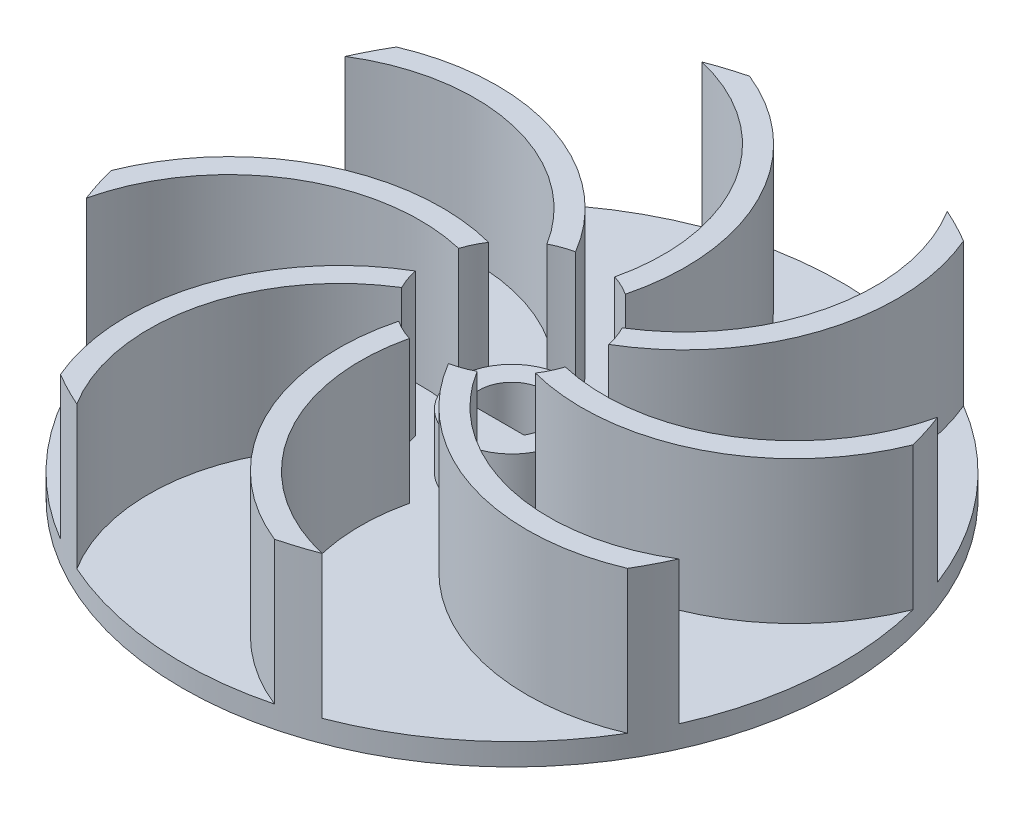
from build123d import *

# Parameters (mm, degrees)
SKETCH1_R           = 30
BOSS_EXTRUDE1_DEPTH = 2
SKETCH2_R           = 5
BOSS_EXTRUDE2_DEPTH = 7
BOSS_EXTRUDE3_DEPTH = 13
CUT_EXTRUDE1_DEPTH  = 16
CIRPATTERN2_COUNT   = 8


with BuildPart() as part:
    # Sketch1 → Boss-Extrude1 (new body)
    with BuildSketch(Plane(origin=(0, 0, 0), x_dir=(1, 0, 0), z_dir=(0, 1, 0))):
        Circle(SKETCH1_R)
    extrude(amount=BOSS_EXTRUDE1_DEPTH)

    # Sketch2 → Boss-Extrude2 (add)
    with BuildSketch(Plane(origin=(0, 0, 0), x_dir=(1, 0, 0), z_dir=(0, 1, 0))):
        Circle(SKETCH2_R)
    extrude(amount=BOSS_EXTRUDE2_DEPTH)

    # Sketch3 → Boss-Extrude3 (add)
    with BuildSketch(Plane(origin=(0, 2, 0), x_dir=(1, 0, 0), z_dir=(0, 1, 0))):
        with BuildLine():
            ThreePointArc((-1.505806951, 7.292266896), (-12.151790035, 15.86929072), (-25.810761164, 15.290670625))
            ThreePointArc((-25.810761164, 15.290670625), (-26.649690738, 13.776573724), (-27.399897799, 12.216611666))
            ThreePointArc((-27.399897799, 12.216611666), (-14.251932533, 14.383859932), (-3.429686075, 6.60922571))
            ThreePointArc((-3.429686075, 6.60922571), (-2.491266579, 7.016993793), (-1.505806951, 7.292266896))
        make_face()
    boss_extrude3 = extrude(amount=BOSS_EXTRUDE3_DEPTH)

    # Sketch4 → Cut-Extrude1 (cut, through all)
    with BuildSketch(Plane(origin=(0, 0, 0), x_dir=(1, 0, 0), z_dir=(0, 1, 0))):
        with BuildLine():
            Line((-2.598076211, -1.5), (2.598076211, -1.5))
            ThreePointArc((2.598076211, -1.5), (0, 3), (-2.598076211, -1.5))
        make_face()
    extrude(amount=CUT_EXTRUDE1_DEPTH, mode=Mode.SUBTRACT)

    # CirPattern2: Boss-Extrude3 ×8 about axis
    cirpattern2_axis = Axis((0, 0, 0), (0, 1, 0))
    for i in range(1, CIRPATTERN2_COUNT):
        add(boss_extrude3.rotate(cirpattern2_axis, i * 360 / CIRPATTERN2_COUNT))


solid = part.part
